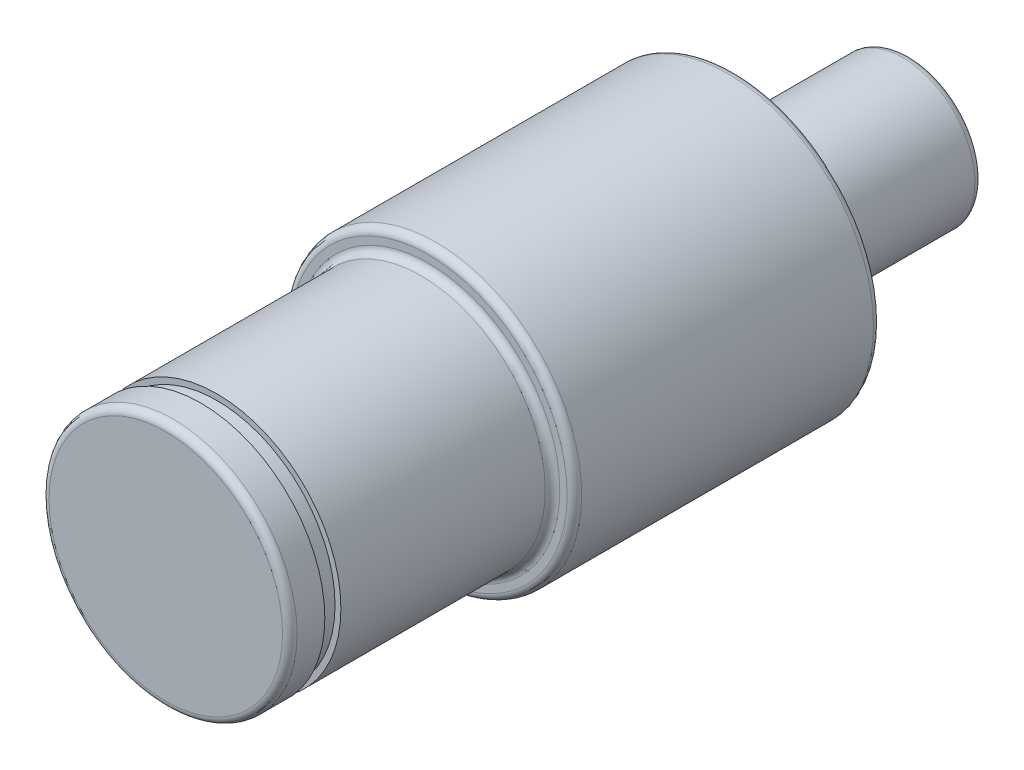
from build123d import *

# Parameters (mm, degrees)
SKETCH_1_R          = 10
EXTRUDE_1_DEPTH     = 21
SKETCH_2_R          = 8.5
EXTRUDE_2_DEPTH     = 18
SKETCH_3_R          = 4.95
EXTRUDE_3_DEPTH     = 12
FILLET_1_R          = 0.5
FILLET_2_R          = 0.5
SKETCH_4_OUTSIDE_W  = 33.664
SKETCH_4_OUTSIDE_H  = 33.664
SKETCH_4_OUTSIDE_R  = 8.1
CUT_EXTRUDE_1_DEPTH = 1.1


with BuildPart() as part:
    # 草图1 → 凸台-拉伸1 (new body)
    with BuildSketch(Plane.XY):
        Circle(SKETCH_1_R)
    extrude(amount=EXTRUDE_1_DEPTH)

    # 草图2 → 凸台-拉伸2 (add)
    with BuildSketch(Plane.XY.offset(21)):
        Circle(SKETCH_2_R)
    extrude(amount=EXTRUDE_2_DEPTH)

    # 草图3 → 凸台-拉伸3 (add)
    with BuildSketch(Plane(origin=(0, 0, 0), x_dir=(-1, 0, 0), z_dir=(0, 0, -1))):
        Circle(SKETCH_3_R)
    extrude(amount=EXTRUDE_3_DEPTH)

    # 圆角1
    fillet_1_edges = [part.edges().sort_by_distance(p)[0] for p in [
        (-8.5, 0, 21),
        (4.95, 0, 0),
    ]]
    fillet(fillet_1_edges, radius=FILLET_1_R)

    # 圆角2
    fillet_2_edges = [part.edges().sort_by_distance(p)[0] for p in [
        (4.95, 0, -12),
        (-10, 0, 0),
        (-10, 0, 21),
        (-8.5, 0, 39),
    ]]
    fillet(fillet_2_edges, radius=FILLET_2_R)

    # 草图4 outside → 切除-拉伸1 (cut)
    with BuildSketch(Plane.XY.offset(35.5)):
        Rectangle(SKETCH_4_OUTSIDE_W, SKETCH_4_OUTSIDE_H)
        Circle(SKETCH_4_OUTSIDE_R, mode=Mode.SUBTRACT)
    extrude(amount=CUT_EXTRUDE_1_DEPTH, mode=Mode.SUBTRACT)


solid = part.part
